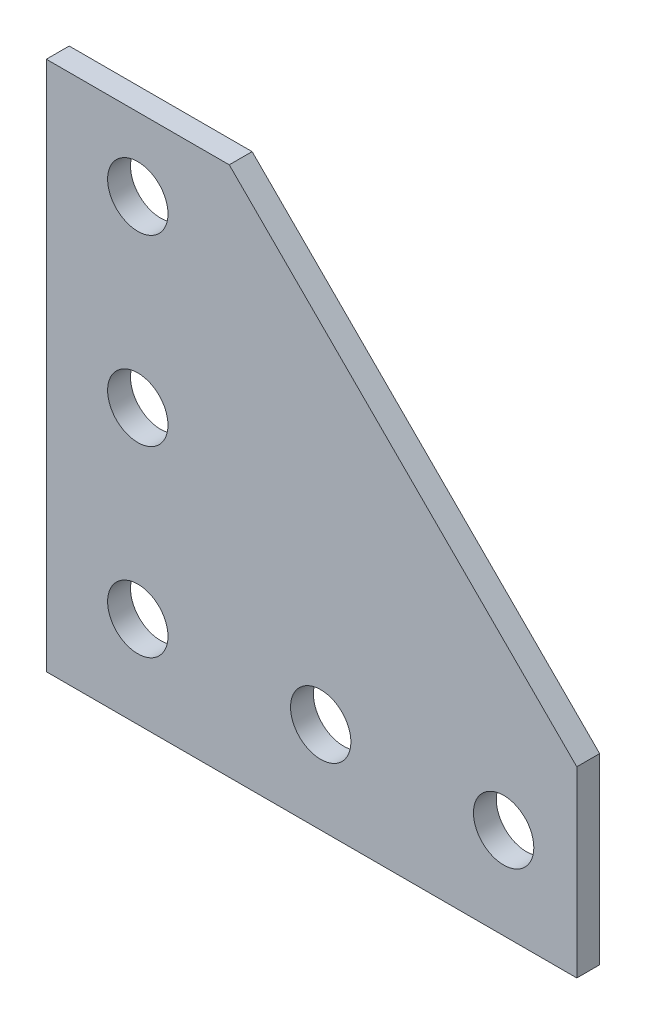
from build123d import *

# Parameters (mm, degrees)
BOSS_EXTRUDE1_DEPTH = 2.5
SKETCH2_R           = 3.3
CUT_EXTRUDE1_DEPTH  = 3.5
LPATTERN1_COUNT     = 3
LPATTERN1_PITCH     = 20
LPATTERN2_COUNT     = 3
LPATTERN2_PITCH     = 20


with BuildPart() as part:
    # Sketch1 → Boss-Extrude1 (new body)
    with BuildSketch(Plane.XY):
        Polygon((-9, 29), (29, -9), (29, -29), (-29, -29), (-29, 29), align=None)
    extrude(amount=BOSS_EXTRUDE1_DEPTH)

    # Sketch2 → Cut-Extrude1 (cut, through all)
    with BuildSketch(Plane.XY.offset(2.5)):
        with Locations((-19, -19)):
            Circle(SKETCH2_R)
    cut_extrude1 = extrude(amount=-CUT_EXTRUDE1_DEPTH, mode=Mode.SUBTRACT)

    # LPattern1: Cut-Extrude1 ×3
    with Locations(*[(i * LPATTERN1_PITCH, 0, 0) for i in range(1, LPATTERN1_COUNT)]):
        add(cut_extrude1, mode=Mode.SUBTRACT)

    # LPattern2: Cut-Extrude1 ×3
    with Locations(*[(0, i * LPATTERN2_PITCH, 0) for i in range(1, LPATTERN2_COUNT)]):
        add(cut_extrude1, mode=Mode.SUBTRACT)


solid = part.part
